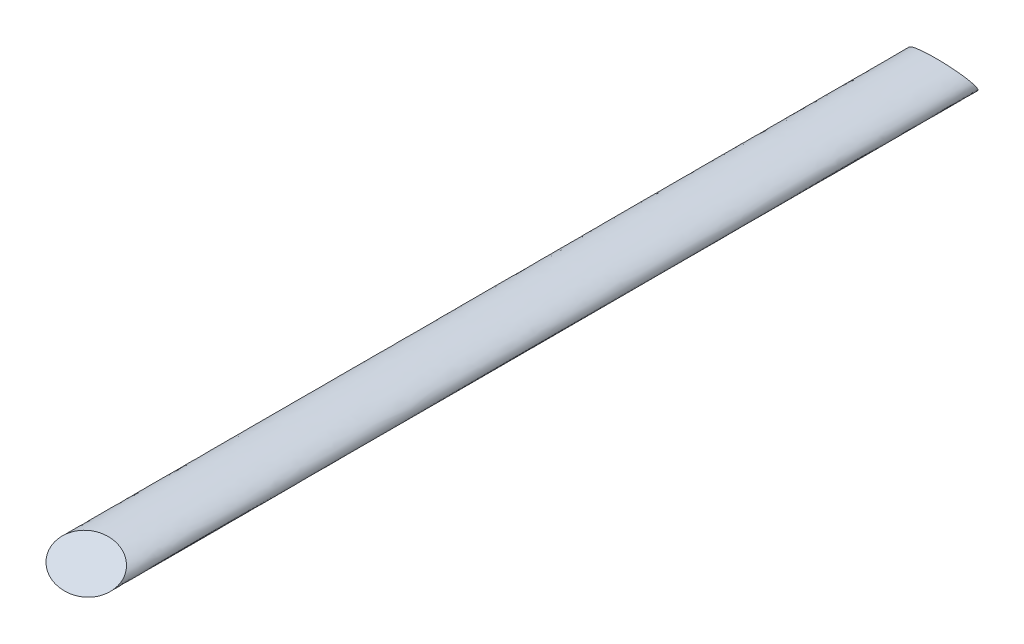
from build123d import *

# Parameters (mm, degrees)
SKETCH1_RX              = 67.7799
SKETCH1_RY              = 25.3619
BOSS_EXTRUDE2_DEPTH     = 1778
CUT_EXTRUDE1_DEPTH      = 68.7799
CUT_EXTRUDE1_DEPTH_BACK = 68.7799


with BuildPart() as part:
    # Sketch1 → Boss-Extrude2 (new body)
    with BuildSketch(Plane.XY):
        with Locations((0, 0)):
            Ellipse(SKETCH1_RX, SKETCH1_RY)
    extrude(amount=BOSS_EXTRUDE2_DEPTH)

    # Sketch2 → Cut-Extrude1 (cut, two sides)
    with BuildSketch(Plane(origin=(0, 0, 0), x_dir=(0, 0, -1), z_dir=(1, 0, 0))) as cut_extrude1_sk:
        Polygon((-1778, -25.3619), (-1645.968257641, 50.866661992), (-2758.274439096, 50.866661992), (-2758.274439096, -25.3619), align=None)
        Polygon((0, -25.3619), (-29.285399584, 25.3619), (0, 25.3619), align=None)
    extrude(amount=CUT_EXTRUDE1_DEPTH, mode=Mode.SUBTRACT)
    extrude(cut_extrude1_sk.sketch, amount=-CUT_EXTRUDE1_DEPTH_BACK, mode=Mode.SUBTRACT)


solid = part.part
